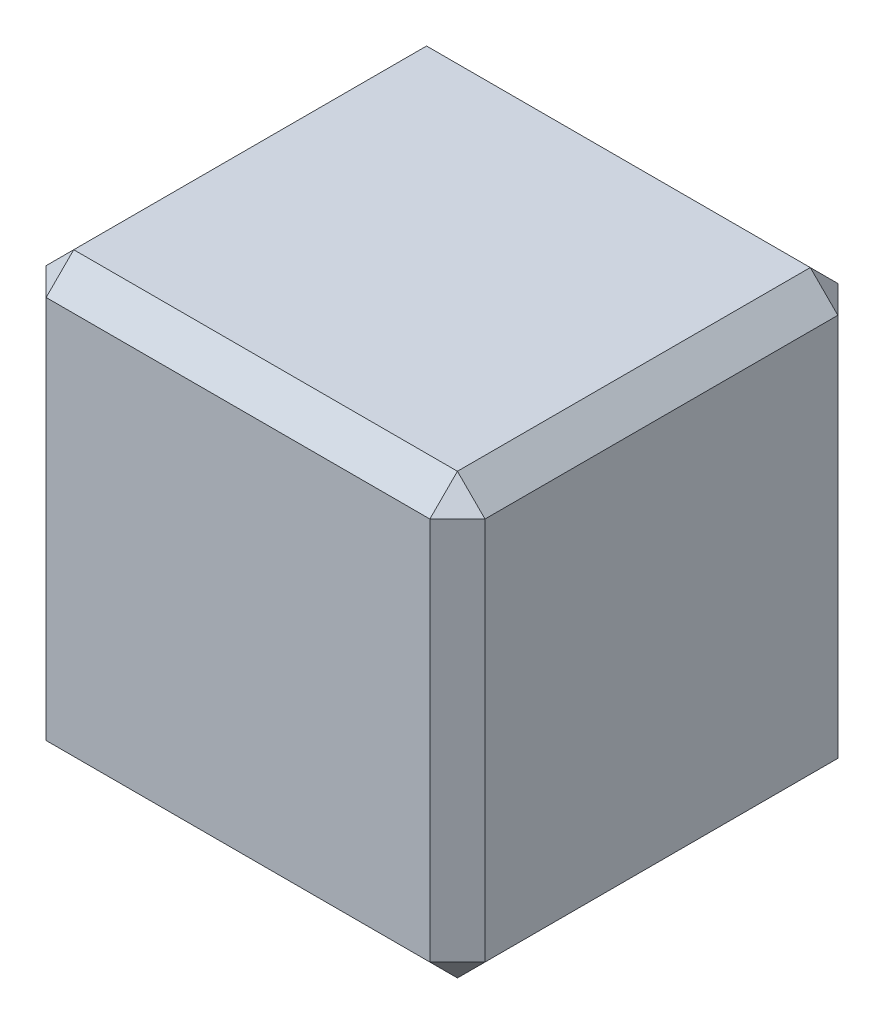
from build123d import *

# Parameters (mm, degrees)
SKETCH1_W           = 25.273
SKETCH1_H           = 25.273
BOSS_EXTRUDE1_DEPTH = 23.495
CHAMFER2_SIZE       = 1.5875


with BuildPart() as part:
    # Sketch1 → Boss-Extrude1 (new body)
    with BuildSketch(Plane.XY):
        Rectangle(SKETCH1_W, SKETCH1_H)
    extrude(amount=BOSS_EXTRUDE1_DEPTH)

    # Chamfer2
    chamfer2_edges = [part.edges().sort_by_distance(p)[0] for p in [
        (-12.6365, 0, 23.495),
        (0, -12.6365, 23.495),
        (12.6365, 0, 23.495),
        (0, -12.6365, 0),
        (-12.6365, 0, 0),
        (0, 12.6365, 0),
        (12.6365, 0, 0),
        (0, 12.6365, 23.495),
        (12.6365, -12.6365, 11.7475),
        (-12.6365, -12.6365, 11.7475),
        (-12.6365, 12.6365, 11.7475),
        (12.6365, 12.6365, 11.7475),
    ]]
    chamfer(chamfer2_edges, length=CHAMFER2_SIZE)


solid = part.part
